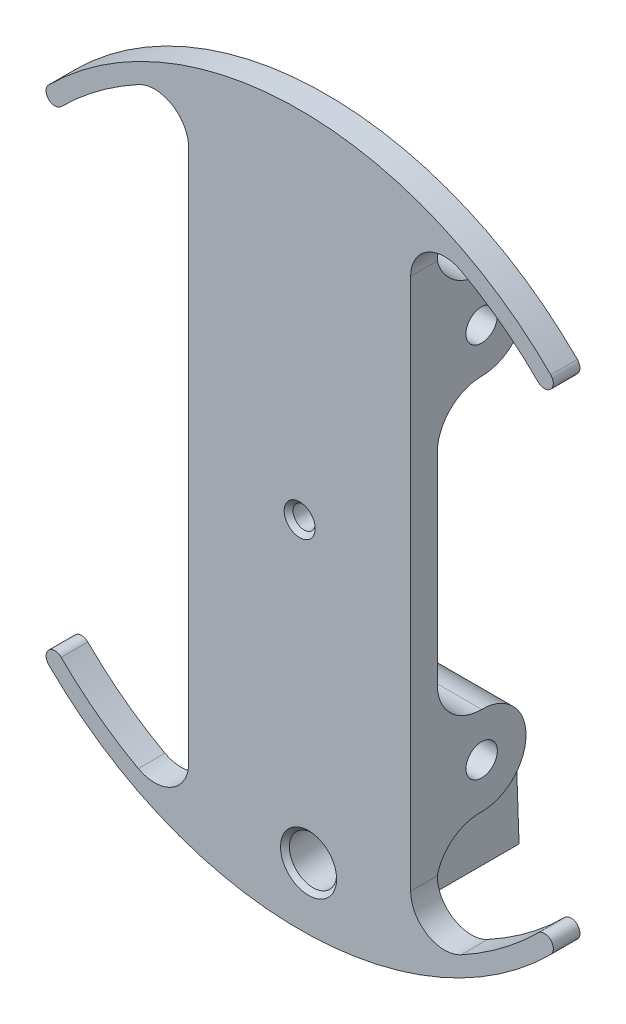
from build123d import *

# Parameters (mm, degrees)
BOSS_EXTRUDE2_DEPTH               = 3.81
BOSS_EXTRUDE4_DEPTH               = 31.75
F_8_CLEARANCE_HOLE1_D             = 4.4958
BOSS_EXTRUDE7_REACH               = 65.711
SKETCH19_R                        = 3.3782
F_1_4_CLEARANCE_HOLE3_D           = 6.7564
F_1_4_CLEARANCE_HOLE3_CSINK_D     = 8.0264
F_1_4_CLEARANCE_HOLE3_CSINK_ANGLE = 90
SKETCH25_R                        = 2.794
CUT_EXTRUDE1_DEPTH                = 3.81
F_2_CLEARANCE_HOLE1_D             = 2.4384
F_2_CLEARANCE_HOLE1_DEPTH         = 3.175
TAP_DRILL_FOR_2_56_TAP1_D         = 1.778
TAP_DRILL_FOR_2_56_TAP1_DEPTH     = 12.7


with BuildPart() as part:
    # Sketch3 → Boss-Extrude2 (new body)
    with BuildSketch(Plane.XY):
        with BuildLine():
            Line((-15.875, -38.1), (-15.875, 38.1))
            ThreePointArc((-15.875, 38.1), (-18.260491841, 42.291797068), (-23.082694008, 42.38179842))
            ThreePointArc((-23.082694008, 42.38179842), (-28.900226452, 38.649767283), (-34.12497326, 34.12497326))
            ThreePointArc((-34.12497326, 34.12497326), (-35.921024484, 34.12497326), (-35.921024484, 35.921024484))
            ThreePointArc((-35.921024484, 35.921024484), (0, 50.8), (35.921024484, 35.921024484))
            ThreePointArc((35.921024484, 35.921024484), (35.921024484, 34.12497326), (34.12497326, 34.12497326))
            ThreePointArc((34.12497326, 34.12497326), (28.900226452, 38.649767283), (23.082694008, 42.38179842))
            ThreePointArc((23.082694008, 42.38179842), (18.260491841, 42.291797068), (15.875, 38.1))
            Line((15.875, 38.1), (15.875, -38.1))
            ThreePointArc((15.875, -38.1), (18.260491841, -42.291797068), (23.082694008, -42.38179842))
            ThreePointArc((23.082694008, -42.38179842), (28.900226452, -38.649767283), (34.12497326, -34.12497326))
            ThreePointArc((34.12497326, -34.12497326), (35.921024484, -34.12497326), (35.921024484, -35.921024484))
            ThreePointArc((35.921024484, -35.921024484), (0, -50.8), (-35.921024484, -35.921024484))
            ThreePointArc((-35.921024484, -35.921024484), (-35.921024484, -34.12497326), (-34.12497326, -34.12497326))
            ThreePointArc((-34.12497326, -34.12497326), (-28.900226452, -38.649767283), (-23.082694008, -42.38179842))
            ThreePointArc((-23.082694008, -42.38179842), (-18.260491841, -42.291797068), (-15.875, -38.1))
        make_face()
    extrude(amount=BOSS_EXTRUDE2_DEPTH)

    # Sketch5 → Boss-Extrude4 (add)
    with BuildSketch(Plane(origin=(15.875, 0, 0), x_dir=(0, 0, -1), z_dir=(1, 0, 0))):
        with BuildLine():
            Line((0, 38.1), (0, 26.99385))
            Line((0, 26.99385), (0, 14.29385))
            ThreePointArc((0, 14.29385), (1.86498297, 18.77886703), (6.35, 20.64385))
            ThreePointArc((6.35, 20.64385), (12.699998494, 26.998224058), (6.341251887, 33.343843974))
            ThreePointArc((6.341251887, 33.343843974), (2.338844583, 34.612930799), (0, 38.1))
        make_face()
        with BuildLine():
            ThreePointArc((6.261703048, -20.644463916), (1.864650947, -18.840779739), (0, -14.469233029))
            Line((0, -14.469233029), (0, -26.99385))
            Line((0, -26.99385), (0, -38.1))
            ThreePointArc((0, -38.1), (2.217611083, -34.670801888), (6.077775616, -33.338012189))
            ThreePointArc((6.077775616, -33.338012189), (6.213919542, -33.33945129), (6.35, -33.34385))
            ThreePointArc((6.35, -33.34385), (12.7, -26.99385), (6.35, -20.64385))
            ThreePointArc((6.35, -20.64385), (6.305852606, -20.644312569), (6.261703048, -20.644463916))
        make_face()
    extrude(amount=-BOSS_EXTRUDE4_DEPTH)

    # #8 Clearance Hole1 (through all)
    with Locations(Plane(origin=(15.875, 0, 0), x_dir=(0, 0, -1), z_dir=(1, 0, 0))):
        with Locations((6.35, 26.99385), (6.35, -26.893399733)):
            Hole(F_8_CLEARANCE_HOLE1_D / 2)

    # Sketch10 → 1/8 (0.125) Diameter Hole1 (revolve, cut)
    with BuildSketch(Plane.YZ):
        Polygon((0, 0), (0, 3.81), (2.2225, 3.81), (1.5875, 3.175), (1.5875, 0.635), (2.2225, 0), align=None)
    revolve(axis=Axis((0, 0, -6.35), (0, 0, 1)), mode=Mode.SUBTRACT)

    # Boss-Extrude7: up to this plane
    boss_extrude7_end = Plane(origin=(-3.551630422, -38.686979812, -19.719207275), z_dir=(0.008390733100517729, 0.03489949670250099, -0.9993556027400597))
    # Sketch19 → Boss-Extrude7 (add, up to the surface)
    with BuildSketch(Plane(origin=(0, 0, 0), x_dir=(-1, 0, 0), z_dir=(0, 0, -1)), mode=Mode.PRIVATE) as boss_extrude7_sk1:
        Polygon((12.7, -38.735), (3.175, -38.735), (3.175, -45.085), (12.7, -45.085), (12.7, -48.26), (-7.62, -48.26), (-7.62, -35.56), (12.7, -35.56), align=None)
        with Locations(Location((-1.27, -41.91, 0), (0, 0, 103.518789087))):
            Circle(SKETCH19_R, mode=Mode.SUBTRACT)
    boss_extrude7_tool1 = split(extrude(boss_extrude7_sk1.sketch, amount=BOSS_EXTRUDE7_REACH, mode=Mode.PRIVATE), bisect_by=boss_extrude7_end, keep=Keep.BOTH, mode=Mode.PRIVATE)
    add(boss_extrude7_tool1.solids().sort_by_distance((-7.9375, -38.495377, 0))[0])

    # 1/4 Clearance Hole3 (through all)
    with Locations(Plane.XY.offset(3.81)):
        with Locations((1.27, -41.91)):
            CounterSinkHole(F_1_4_CLEARANCE_HOLE3_D / 2, F_1_4_CLEARANCE_HOLE3_CSINK_D / 2, counter_sink_angle=F_1_4_CLEARANCE_HOLE3_CSINK_ANGLE)

    # Sketch25 → Cut-Extrude1 (cut)
    with BuildSketch(Plane.ZY.offset(3.175)):
        with Locations(Location((-7.62, -41.91, 0), (0, 0, 270))):
            Circle(SKETCH25_R)
    extrude(amount=-CUT_EXTRUDE1_DEPTH, mode=Mode.SUBTRACT)

    # #2 Clearance Hole1
    with Locations(Plane(origin=(0, -48.26, 0), x_dir=(-1, 0, 0), z_dir=(0, -1, 0))):
        with Locations((9.825, 14.7), (9.825, 5.2)):
            Hole(F_2_CLEARANCE_HOLE1_D / 2, depth=F_2_CLEARANCE_HOLE1_DEPTH)

    # Tap Drill for #2-56 Tap1
    with Locations(Plane(origin=(0, -48.26, 0), x_dir=(-1, 0, 0), z_dir=(0, -1, 0))):
        with Locations((9.825, 14.7), (9.825, 5.2)):
            Hole(TAP_DRILL_FOR_2_56_TAP1_D / 2, depth=TAP_DRILL_FOR_2_56_TAP1_DEPTH)


solid = part.part
